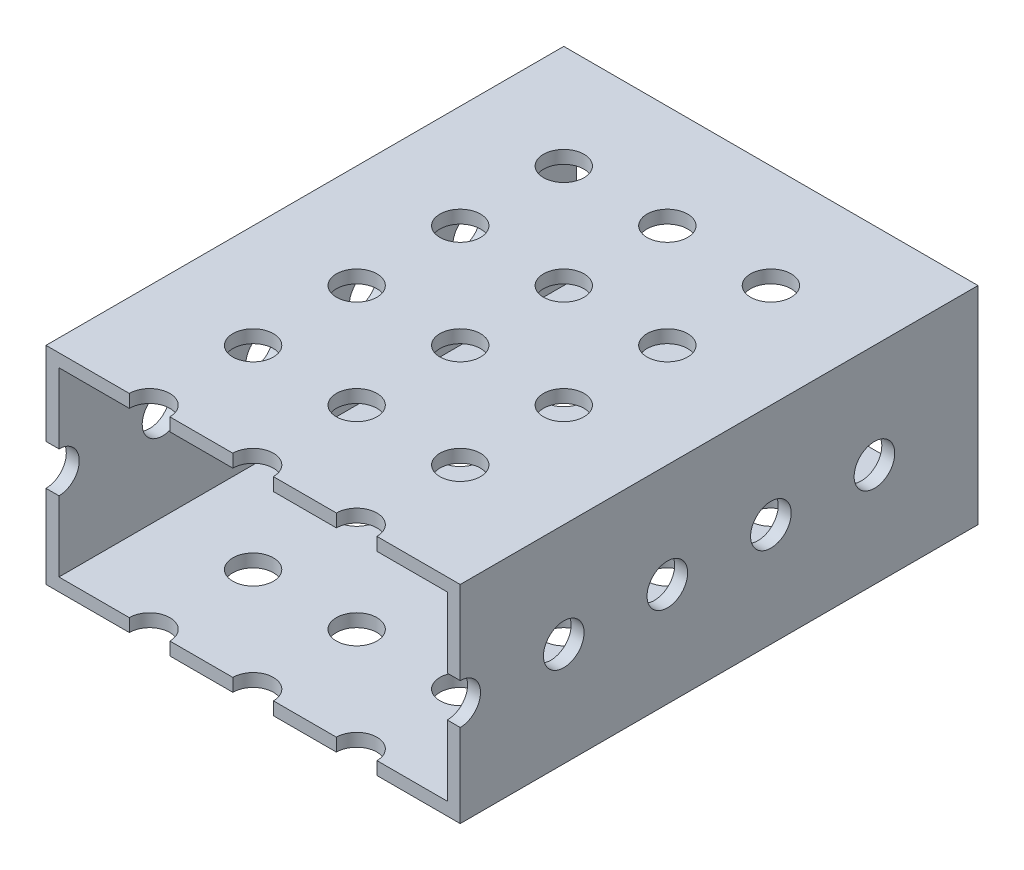
from build123d import *

# Parameters (mm, degrees)
SKETCH1_W           = 50.8
SKETCH1_H           = 25.4
SKETCH1_W_2         = 47.625
SKETCH1_H_2         = 22.225
BOSS_EXTRUDE1_DEPTH = 63.5
SKETCH2_R           = 2.4892
CUT_EXTRUDE1_DEPTH  = 26.4
SKETCH3_R           = 2.4892
CUT_EXTRUDE2_DEPTH  = 51.8


with BuildPart() as part:
    # Sketch1 → Boss-Extrude1 (new body)
    with BuildSketch(Plane.XY):
        with Locations((25.4, 12.7)):
            Rectangle(SKETCH1_W, SKETCH1_H)
        with Locations((25.4, 12.7)):
            Rectangle(SKETCH1_W_2, SKETCH1_H_2, mode=Mode.SUBTRACT)
    extrude(amount=BOSS_EXTRUDE1_DEPTH)

    # Sketch2 → Cut-Extrude1 (cut, through all)
    with BuildSketch(Plane(origin=(0, 25.4, 0), x_dir=(1, 0, 0), z_dir=(0, 1, 0))):
        with Locations((12.7, -12.7)):
            Circle(SKETCH2_R)
        with Locations((25.4, -12.7)):
            Circle(SKETCH2_R)
        with Locations((38.1, -12.7)):
            Circle(SKETCH2_R)
        with Locations((25.4, -25.4)):
            Circle(SKETCH2_R)
        with Locations((38.1, -25.4)):
            Circle(SKETCH2_R)
        with Locations((25.4, -38.1)):
            Circle(SKETCH2_R)
        with Locations((38.1, -38.1)):
            Circle(SKETCH2_R)
        with Locations((25.4, -50.8)):
            Circle(SKETCH2_R)
        with Locations((38.1, -50.8)):
            Circle(SKETCH2_R)
        with Locations((25.4, -63.5)):
            Circle(SKETCH2_R)
        with Locations((38.1, -63.5)):
            Circle(SKETCH2_R)
        with Locations((12.7, -25.4)):
            Circle(SKETCH2_R)
        with Locations((12.7, -38.1)):
            Circle(SKETCH2_R)
        with Locations((12.7, -50.8)):
            Circle(SKETCH2_R)
        with Locations((12.7, -63.5)):
            Circle(SKETCH2_R)
    extrude(amount=-CUT_EXTRUDE1_DEPTH, mode=Mode.SUBTRACT)

    # Sketch3 → Cut-Extrude2 (cut, through all)
    with BuildSketch(Plane.ZY):
        with Locations((12.7, 12.7)):
            Circle(SKETCH3_R)
        with Locations((25.4, 12.7)):
            Circle(SKETCH3_R)
        with Locations((38.1, 12.7)):
            Circle(SKETCH3_R)
        with Locations((50.8, 12.7)):
            Circle(SKETCH3_R)
        with Locations((63.5, 12.7)):
            Circle(SKETCH3_R)
    extrude(amount=-CUT_EXTRUDE2_DEPTH, mode=Mode.SUBTRACT)


solid = part.part
